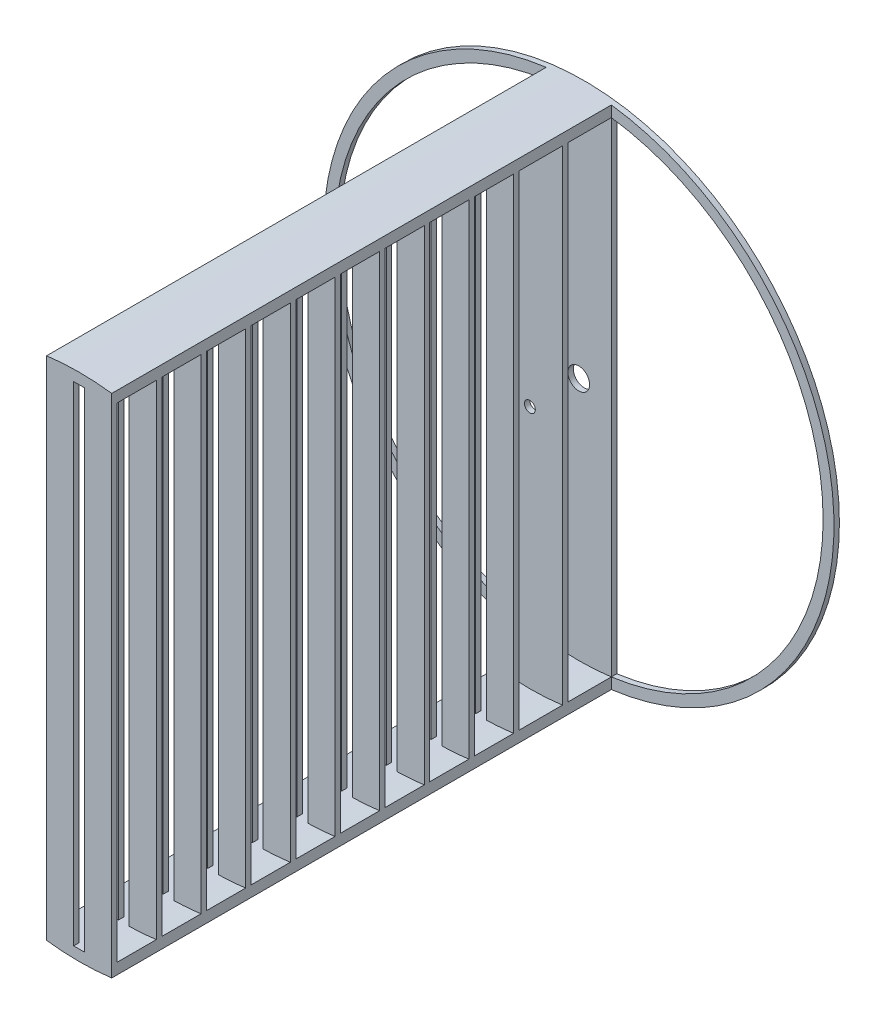
from build123d import *

# Parameters (mm, degrees)
SKETCH1_R           = 596.9
SKETCH1_R_2         = 25.4
BOSS_EXTRUDE1_DEPTH = 12.7
BOSS_EXTRUDE2_DEPTH = 1168.4
SKETCH3_R           = 12.7
BOSS_EXTRUDE3_DEPTH = 12.7
BOSS_EXTRUDE4_DEPTH = 12.7
LPATTERN1_COUNT     = 10
LPATTERN1_PITCH     = 104.422222


with BuildPart() as part:
    # Sketch1 → Boss-Extrude1 (new body)
    with BuildSketch(Plane.XY):
        Circle(SKETCH1_R)
        Circle(SKETCH1_R_2, mode=Mode.SUBTRACT)
        with BuildLine():
            Line((76.2, 566.397219), (76.2, -566.397219))
            ThreePointArc((76.2, -566.397219), (571.5, 0), (76.2, 566.397219))
        make_face(mode=Mode.SUBTRACT)
        with BuildLine():
            Line((-76.2, 566.397219), (-76.2, -566.397219))
            ThreePointArc((-76.2, -566.397219), (-571.5, 0), (-76.2, 566.397219))
        make_face(mode=Mode.SUBTRACT)
    extrude(amount=BOSS_EXTRUDE1_DEPTH)

    # Sketch2 → Boss-Extrude2 (add)
    with BuildSketch(Plane.XY.offset(12.7)):
        with BuildLine():
            Line((-76.2, -566.397219), (-76.2, -592.016191))
            ThreePointArc((-76.2, -592.016191), (0, -596.9), (76.2, -592.016191))
            Line((76.2, -592.016191), (76.2, -566.397219))
            ThreePointArc((76.2, -566.397219), (0, -571.5), (-76.2, -566.397219))
        make_face()
    boss_extrude2 = extrude(amount=BOSS_EXTRUDE2_DEPTH)

    # Mirror1: Boss-Extrude2 across plane
    add(boss_extrude2.mirror(Plane.ZX))

    # Sketch3 → Boss-Extrude3 (add)
    with BuildSketch(Plane.XY.offset(114.3)):
        with BuildLine():
            Line((76.2, -592.016191), (76.2, 592.016191))
            ThreePointArc((76.2, 592.016191), (0, 596.9), (-76.2, 592.016191))
            Line((-76.2, 592.016191), (-76.2, -592.016191))
            ThreePointArc((-76.2, -592.016191), (0, -596.9), (76.2, -592.016191))
        make_face()
        Circle(SKETCH3_R, mode=Mode.SUBTRACT)
    extrude(amount=BOSS_EXTRUDE3_DEPTH)

    # Sketch4 → Boss-Extrude4 (add)
    with BuildSketch(Plane.XY.offset(228.6)):
        with BuildLine():
            Line((76.2, -592.016191), (76.2, 592.016191))
            ThreePointArc((76.2, 592.016191), (0, 596.9), (-76.2, 592.016191))
            Line((-76.2, 592.016191), (-76.2, -592.016191))
            ThreePointArc((-76.2, -592.016191), (0, -596.9), (76.2, -592.016191))
        make_face()
        with BuildLine():
            Line((12.7, -571.358871), (12.7, 571.358871))
            ThreePointArc((12.7, 571.358871), (0, 571.5), (-12.7, 571.358871))
            Line((-12.7, 571.358871), (-12.7, -571.358871))
            ThreePointArc((-12.7, -571.358871), (0, -571.5), (12.7, -571.358871))
        make_face(mode=Mode.SUBTRACT)
    boss_extrude4 = extrude(amount=BOSS_EXTRUDE4_DEPTH)

    # LPattern1: Boss-Extrude4 ×10
    with Locations(*[(0, 0, i * LPATTERN1_PITCH) for i in range(1, LPATTERN1_COUNT)]):
        add(boss_extrude4)


solid = part.part
